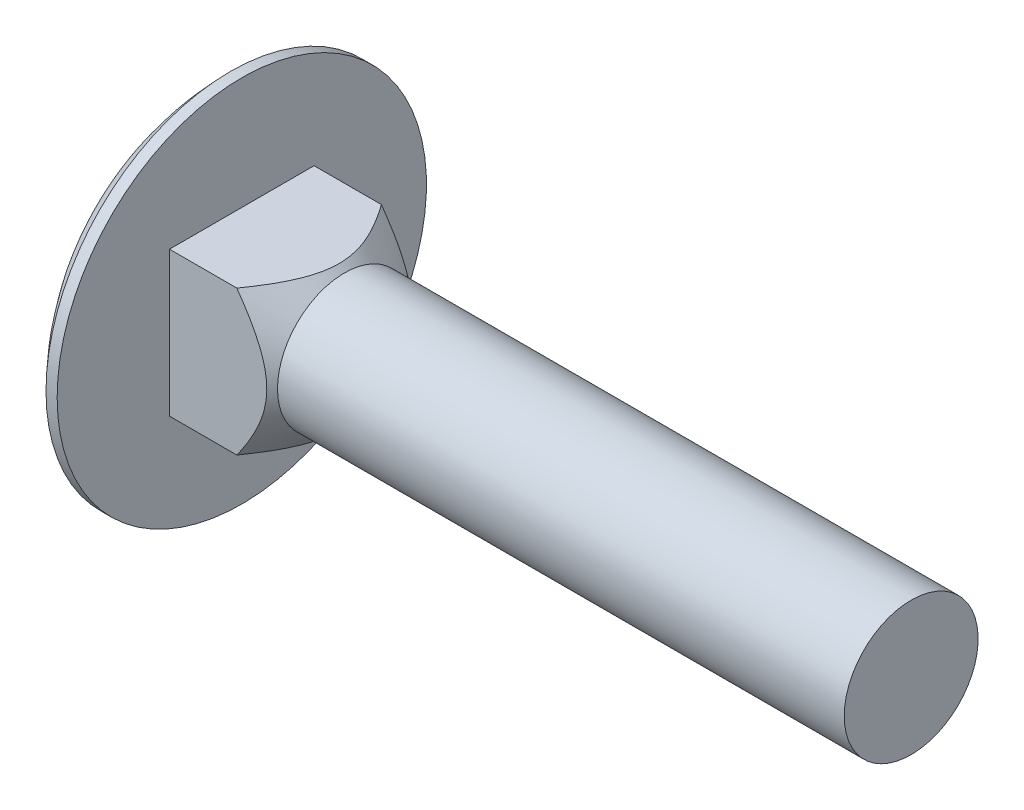
from build123d import *

# Parameters (mm, degrees)
SKETCH_2_W      = 6.48
SKETCH_2_H      = 6.48
EXTRUDE_1_DEPTH = 4.6


with BuildPart() as part:
    # Эскиз1 → Повернуть1 (revolve)
    with BuildSketch(Plane.XY):
        with BuildLine():
            Line((30, 0), (-3.88, 0))
            ThreePointArc((-3.88, 0), (-3.002420637, 4.469340695), (-0.5, 8.275))
            Line((-0.5, 8.275), (0, 8.275))
            Line((0, 8.275), (0, 3))
            Line((0, 3), (30, 3))
            Line((30, 3), (30, 0))
        make_face()
    revolve(axis=Axis((-946.390579576, 0, 0), (1, 0, 0)))

    # Эскиз2 → Бобышка-Вытянуть1 (add)
    with BuildSketch(Plane(origin=(0, 0, 0), x_dir=(0, 0, -1), z_dir=(1, 0, 0))):
        Rectangle(SKETCH_2_W, SKETCH_2_H)
    extrude(amount=EXTRUDE_1_DEPTH)


with BuildPart() as body_2:
    # Эскиз3 → Повернуть2 (revolve)
    with BuildSketch(Plane(origin=(0, 0, 0), x_dir=(-1, 0, 0), z_dir=(0, -0.707106781, 0.707106781))):
        Polygon((-4.6, 3), (-2.017948058, 5.582051942), (-7.182051942, 5.582051942), align=None)
    revolve(axis=Axis((1000, 0, 0), (-1, 0, 0)))


with BuildPart() as part_1:
    add(part.part)

    # Combine 1: cut body 2
    add(body_2.part, mode=Mode.SUBTRACT)


solid = part_1.part
